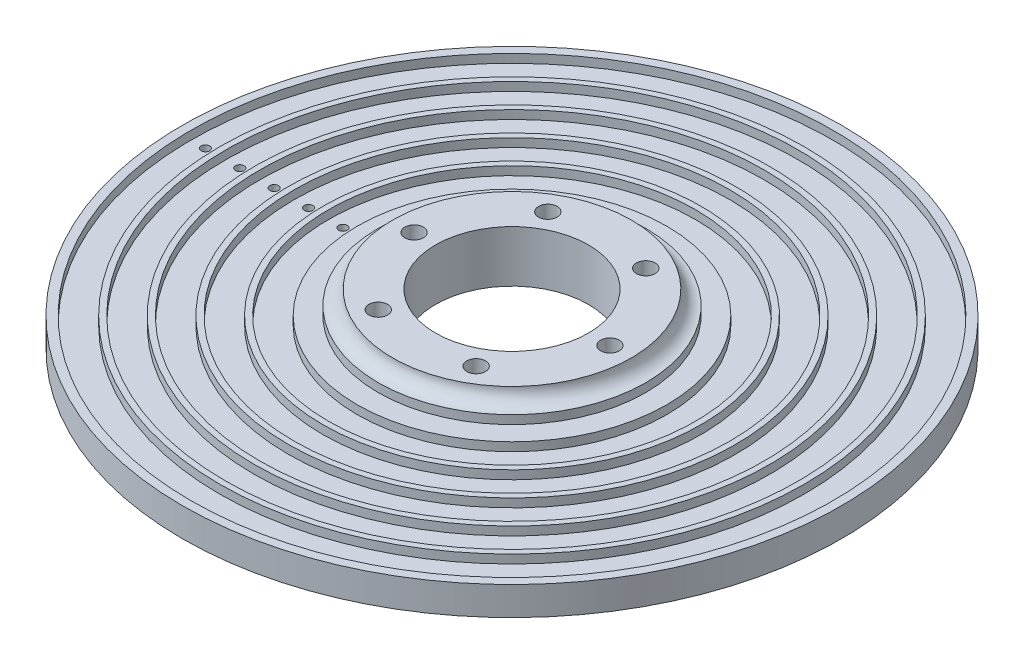
from build123d import *

# Parameters (mm, degrees)
SKETCH1_R           = 23.335
SKETCH1_R_2         = 13.335
BOSS_EXTRUDE1_DEPTH = 4
SKETCH3_R           = 57.5
SKETCH3_R_2         = 13.335
BOSS_EXTRUDE2_DEPTH = 5
SKETCH4_R           = 56
SKETCH4_R_2         = 51
SKETCH4_R_3         = 50
SKETCH4_R_4         = 45
SKETCH4_R_5         = 44
SKETCH4_R_6         = 39
SKETCH4_R_7         = 38
SKETCH4_R_8         = 33
SKETCH4_R_9         = 32
SKETCH4_R_10        = 27
CUT_EXTRUDE2_DEPTH  = 1.5
SKETCH5_R           = 2.5
SKETCH2_R           = 1.625
CUT_EXTRUDE1_DEPTH  = 82.813813015
SKETCH6_R           = 0.75
CUT_EXTRUDE3_DEPTH  = 82.503067427
SKETCH7_R           = 3
CUT_EXTRUDE4_DEPTH  = 3


with BuildPart() as part:
    # Sketch1 → Boss-Extrude1 (new body)
    with BuildSketch(Plane(origin=(0, 0, 0), x_dir=(1, 0, 0), z_dir=(0, 1, 0))):
        with Locations(Location((0, 0, 0), (0, 0, 270))):
            Circle(SKETCH1_R)
        with Locations(Location((0, 0, 0), (0, 0, 270))):
            Circle(SKETCH1_R_2, mode=Mode.SUBTRACT)
    extrude(amount=BOSS_EXTRUDE1_DEPTH)

    # Sketch3 → Boss-Extrude2 (add)
    with BuildSketch(Plane.XZ):
        with Locations(Location((0, 0, 0), (0, 0, 270))):
            Circle(SKETCH3_R)
        with Locations(Location((0, 0, 0), (0, 0, 270))):
            Circle(SKETCH3_R_2, mode=Mode.SUBTRACT)
    extrude(amount=BOSS_EXTRUDE2_DEPTH)

    # Sketch4 → Cut-Extrude2 (cut)
    with BuildSketch(Plane(origin=(0, 0, 0), x_dir=(1, 0, 0), z_dir=(0, 1, 0))):
        with Locations(Location((0, 0, 0), (0, 0, 270))):
            Circle(SKETCH4_R)
        with Locations(Location((0, 0, 0), (0, 0, 270))):
            Circle(SKETCH4_R_2, mode=Mode.SUBTRACT)
        with Locations(Location((0, 0, 0), (0, 0, 270))):
            Circle(SKETCH4_R_3)
        with Locations(Location((0, 0, 0), (0, 0, 270))):
            Circle(SKETCH4_R_4, mode=Mode.SUBTRACT)
        with Locations(Location((0, 0, 0), (0, 0, 270))):
            Circle(SKETCH4_R_5)
        with Locations(Location((0, 0, 0), (0, 0, 270))):
            Circle(SKETCH4_R_6, mode=Mode.SUBTRACT)
        with Locations(Location((0, 0, 0), (0, 0, 270))):
            Circle(SKETCH4_R_7)
        with Locations(Location((0, 0, 0), (0, 0, 270))):
            Circle(SKETCH4_R_8, mode=Mode.SUBTRACT)
        with Locations(Location((0, 0, 0), (0, 0, 270))):
            Circle(SKETCH4_R_9)
        with Locations(Location((0, 0, 0), (0, 0, 270))):
            Circle(SKETCH4_R_10, mode=Mode.SUBTRACT)
    extrude(amount=-CUT_EXTRUDE2_DEPTH, mode=Mode.SUBTRACT)

    # Sketch5 → Cut-Revolve1 (revolve, cut)
    with BuildSketch(Plane.XY, mode=Mode.PRIVATE) as cut_revolve1_sk:
        with Locations((-23.335, 4)):
            Circle(SKETCH5_R)
    revolve(cut_revolve1_sk.sketch.rotate(Axis((0, 4, 0), (0, -1, 0)), 90), axis=Axis((0, 4, 0), (0, -1, 0)), mode=Mode.SUBTRACT)

    # Sketch2 → Cut-Extrude1 (cut, through all)
    with BuildSketch(Plane(origin=(0, 4, 0), x_dir=(1, 0, 0), z_dir=(0, 1, 0))):
        with Locations(Location((-8.5425, 14.796044024, 0), (0, 0, 270))):
            Circle(SKETCH2_R)
        with Locations(Location((-17.085, 0, 0), (0, 0, 270))):
            Circle(SKETCH2_R)
        with Locations(Location((-8.5425, -14.796044024, 0), (0, 0, 270))):
            Circle(SKETCH2_R)
        with Locations(Location((8.5425, -14.796044024, 0), (0, 0, 270))):
            Circle(SKETCH2_R)
        with Locations(Location((17.085, 0, 0), (0, 0, 270))):
            Circle(SKETCH2_R)
        with Locations(Location((8.5425, 14.796044024, 0), (0, 0, 270))):
            Circle(SKETCH2_R)
    extrude(amount=-CUT_EXTRUDE1_DEPTH, mode=Mode.SUBTRACT)

    # Sketch6 → Cut-Extrude3 (cut, through all)
    with BuildSketch(Plane(origin=(0, -1.5, 0), x_dir=(1, 0, 0), z_dir=(0, 1, 0))):
        with Locations(Location((-53.5, 0, 0), (0, 0, 270))):
            Circle(SKETCH6_R)
        with Locations(Location((-47.5, 0, 0), (0, 0, 270))):
            Circle(SKETCH6_R)
        with Locations(Location((-41.5, 0, 0), (0, 0, 270))):
            Circle(SKETCH6_R)
        with Locations(Location((-35.5, 0, 0), (0, 0, 270))):
            Circle(SKETCH6_R)
        with Locations(Location((-29.5, 0, 0), (0, 0, 270))):
            Circle(SKETCH6_R)
    extrude(amount=-CUT_EXTRUDE3_DEPTH, mode=Mode.SUBTRACT)

    # Sketch7 → Cut-Extrude4 (cut)
    with BuildSketch(Plane.XZ.offset(5)):
        with Locations(Location((-17.085, 0, 0), (0, 0, 270))):
            Circle(SKETCH7_R)
        with Locations(Location((8.5425, -14.796044024, 0), (0, 0, 270))):
            Circle(SKETCH7_R)
        with Locations(Location((8.5425, 14.796044024, 0), (0, 0, 270))):
            Circle(SKETCH7_R)
    extrude(amount=-CUT_EXTRUDE4_DEPTH, mode=Mode.SUBTRACT)


solid = part.part
